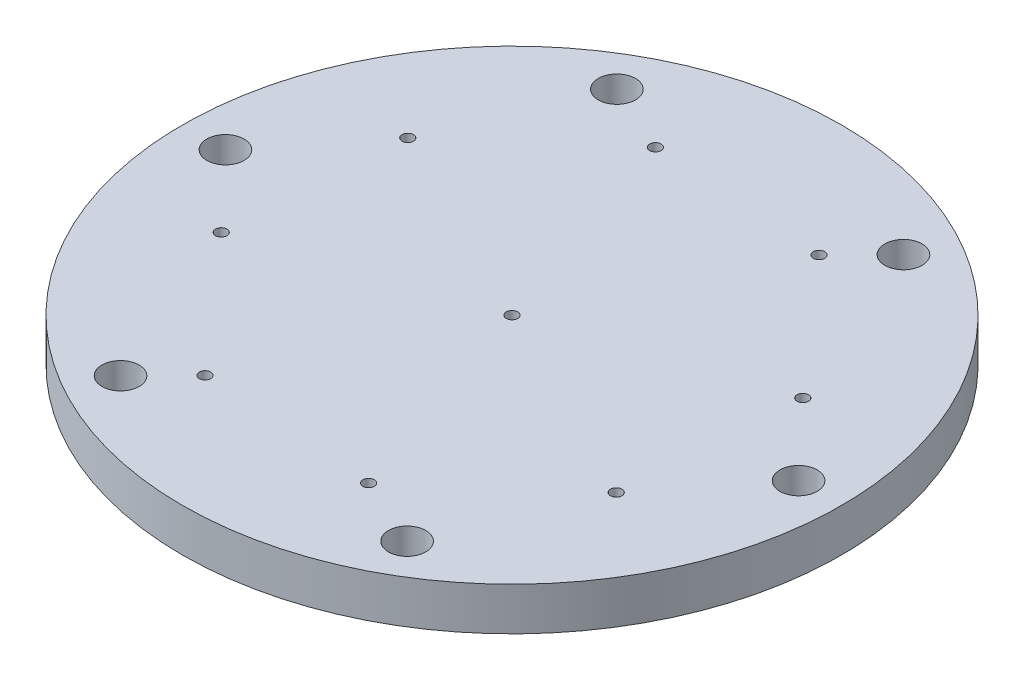
from build123d import *

# Parameters (mm, degrees)
SKETCH1_R           = 115
SKETCH1_R_2         = 65
SKETCH1_R_3         = 6.5
SKETCH1_R_4         = 2
BOSS_EXTRUDE1_DEPTH = 15
SKETCH2_R           = 65
BOSS_EXTRUDE2_DEPTH = 5
SKETCH4_R           = 2
CUT_EXTRUDE1_DEPTH  = 5


with BuildPart() as part:
    # Sketch1 → Boss-Extrude1 (new body)
    with BuildSketch(Plane(origin=(0, 0, 0), x_dir=(1, 0, 0), z_dir=(0, 1, 0))):
        Circle(SKETCH1_R)
        Circle(SKETCH1_R_2, mode=Mode.SUBTRACT)
        with Locations((50, 86.602540378)):
            Circle(SKETCH1_R_3, mode=Mode.SUBTRACT)
        with Locations((100, 0)):
            Circle(SKETCH1_R_3, mode=Mode.SUBTRACT)
        with Locations((50, -86.602540378)):
            Circle(SKETCH1_R_3, mode=Mode.SUBTRACT)
        with Locations((-50, -86.602540378)):
            Circle(SKETCH1_R_3, mode=Mode.SUBTRACT)
        with Locations((-100, 0)):
            Circle(SKETCH1_R_3, mode=Mode.SUBTRACT)
        with Locations((-50, 86.602540378)):
            Circle(SKETCH1_R_3, mode=Mode.SUBTRACT)
        with Locations((-25.715157224, 75.75441036)):
            Circle(SKETCH1_R_4, mode=Mode.SUBTRACT)
        with Locations((35.383095218, 71.749819323)):
            Circle(SKETCH1_R_4, mode=Mode.SUBTRACT)
        with Locations((75.75441036, 25.715157224)):
            Circle(SKETCH1_R_4, mode=Mode.SUBTRACT)
        with Locations((71.749819323, -35.383095218)):
            Circle(SKETCH1_R_4, mode=Mode.SUBTRACT)
        with Locations((25.715157224, -75.75441036)):
            Circle(SKETCH1_R_4, mode=Mode.SUBTRACT)
        with Locations((-35.383095218, -71.749819323)):
            Circle(SKETCH1_R_4, mode=Mode.SUBTRACT)
        with Locations((-75.75441036, -25.715157224)):
            Circle(SKETCH1_R_4, mode=Mode.SUBTRACT)
        with Locations((-71.749819323, 35.383095218)):
            Circle(SKETCH1_R_4, mode=Mode.SUBTRACT)
    extrude(amount=BOSS_EXTRUDE1_DEPTH)

    # Sketch2 → Boss-Extrude2 (add)
    with BuildSketch(Plane(origin=(0, 15, 0), x_dir=(1, 0, 0), z_dir=(0, 1, 0))):
        Circle(SKETCH2_R)
    extrude(amount=-BOSS_EXTRUDE2_DEPTH)

    # Sketch4 → Cut-Extrude1 (cut)
    with BuildSketch(Plane.XZ.offset(-10)):
        Circle(SKETCH4_R)
    extrude(amount=-CUT_EXTRUDE1_DEPTH, mode=Mode.SUBTRACT)


solid = part.part
